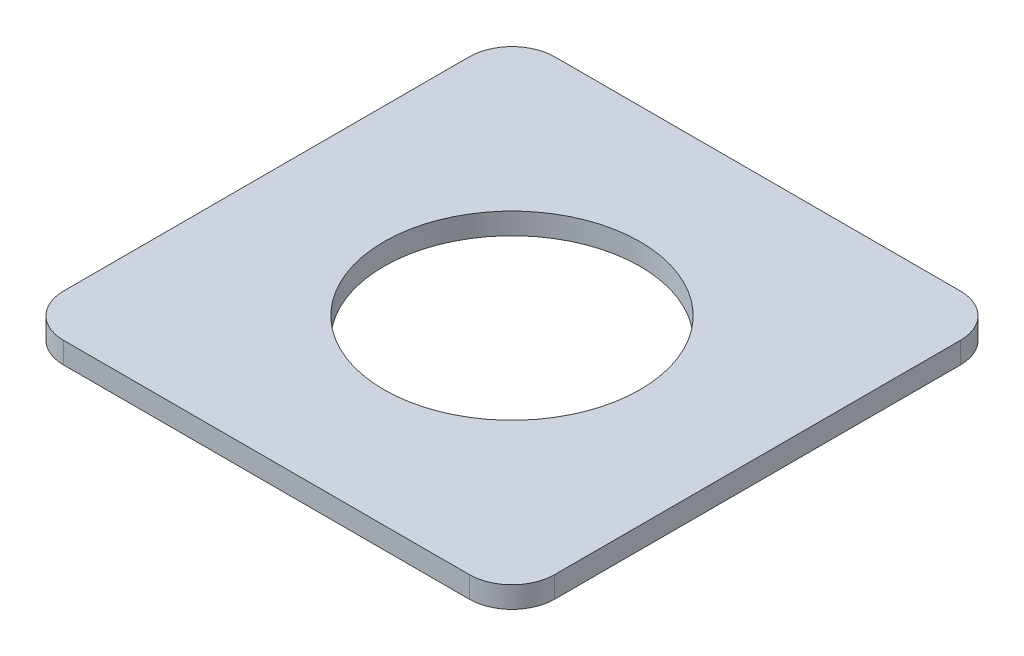
from build123d import *

# Parameters (mm, degrees)
SKETCH_2_R      = 6
EXTRUDE_1_DEPTH = 1


with BuildPart() as part:
    # Эскиз2 → Бобышка-Вытянуть1 (new body)
    with BuildSketch(Plane(origin=(0, 0, 0), x_dir=(1, 0, 0), z_dir=(0, 1, 0))):
        with BuildLine():
            Line((9.5, -11.5), (-9.5, -11.5))
            ThreePointArc((-9.5, -11.5), (-10.914213562, -10.914213562), (-11.5, -9.5))
            Line((-11.5, -9.5), (-11.5, 9.5))
            ThreePointArc((-11.5, 9.5), (-10.914213562, 10.914213562), (-9.5, 11.5))
            Line((-9.5, 11.5), (9.5, 11.5))
            ThreePointArc((9.5, 11.5), (10.914213562, 10.914213562), (11.5, 9.5))
            Line((11.5, 9.5), (11.5, -9.5))
            ThreePointArc((11.5, -9.5), (10.914213562, -10.914213562), (9.5, -11.5))
        make_face()
        Circle(SKETCH_2_R, mode=Mode.SUBTRACT)
    extrude(amount=EXTRUDE_1_DEPTH)


solid = part.part
